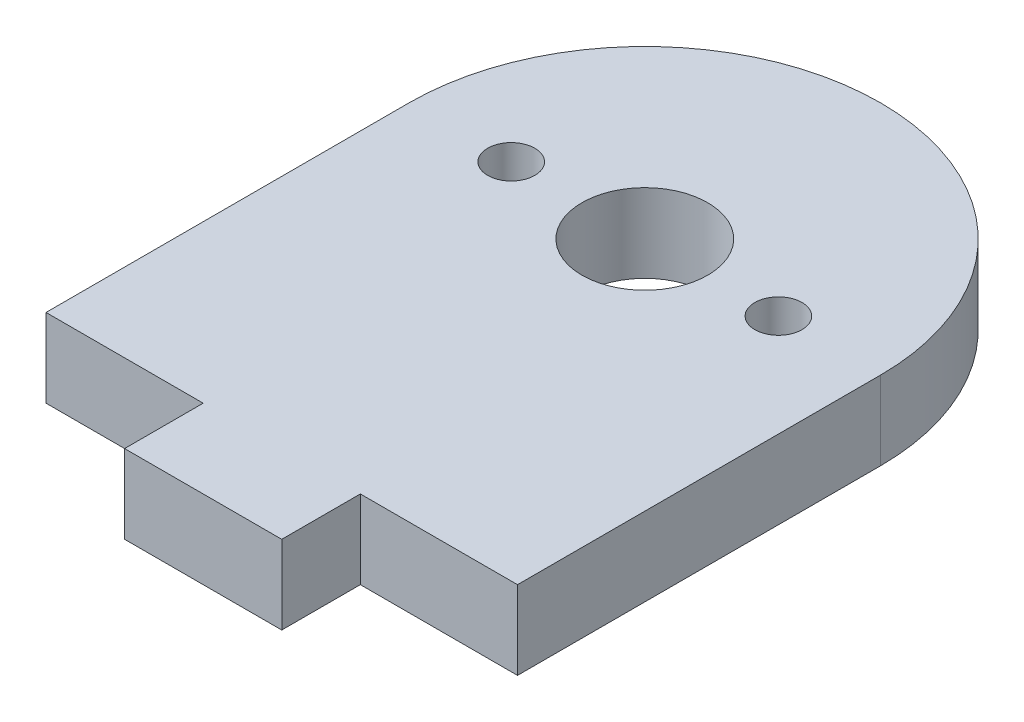
from build123d import *

# Parameters (mm, degrees)
EXTRUDE_1_DEPTH = 5
SKETCH_2_R      = 12.5
SKETCH_2_R_2    = 1.5
SKETCH_2_R_3    = 4
EXTRUDE_2_DEPTH = 5
SKETCH_3_W      = 10
SKETCH_3_H      = 5
EXTRUDE_3_DEPTH = 5


with BuildPart() as part:
    # 草图1 → 凸台-拉伸1 (new body)
    with BuildSketch(Plane(origin=(0, 0, 0), x_dir=(1, 0, 0), z_dir=(0, 1, 0))):
        with BuildLine():
            ThreePointArc((15, 11.55), (0, 26.55), (-15, 11.55))
            Line((-15, 11.55), (-12.5, 11.55))
            ThreePointArc((-12.5, 11.55), (0, 24.05), (12.5, 11.55))
            Line((12.5, 11.55), (15, 11.55))
        make_face()
        with BuildLine():
            Line((-12.5, 11.55), (-15, 11.55))
            ThreePointArc((-15, 11.55), (0, -3.45), (15, 11.55))
            Line((15, 11.55), (12.5, 11.55))
            ThreePointArc((12.5, 11.55), (0, -0.95), (-12.5, 11.55))
        make_face()
        with BuildLine():
            ThreePointArc((15, 11.55), (0, 26.55), (-15, 11.55))
            Line((-15, 11.55), (-12.5, 11.55))
            ThreePointArc((-12.5, 11.55), (0, 24.05), (12.5, 11.55))
            Line((12.5, 11.55), (15, 11.55))
        make_face()
        with BuildLine():
            Line((-12.5, 11.55), (-15, 11.55))
            ThreePointArc((-15, 11.55), (0, -3.45), (15, 11.55))
            Line((15, 11.55), (12.5, 11.55))
            ThreePointArc((12.5, 11.55), (0, -0.95), (-12.5, 11.55))
        make_face()
        with BuildLine():
            Line((-15, 11.55), (-15, -11.55))
            Line((-15, -11.55), (15, -11.55))
            Line((15, -11.55), (15, 11.55))
            ThreePointArc((15, 11.55), (0, -3.45), (-15, 11.55))
        make_face()
    extrude(amount=EXTRUDE_1_DEPTH)

    # 草图2 → 凸台-拉伸2 (add)
    with BuildSketch(Plane(origin=(0, 5, 0), x_dir=(1, 0, 0), z_dir=(0, 1, 0))):
        with Locations((0, 11.55)):
            Circle(SKETCH_2_R)
        with Locations((-8.5, 11.55)):
            Circle(SKETCH_2_R_2, mode=Mode.SUBTRACT)
        with Locations((8.5, 11.55)):
            Circle(SKETCH_2_R_2, mode=Mode.SUBTRACT)
        with Locations((0, 11.55)):
            Circle(SKETCH_2_R_3, mode=Mode.SUBTRACT)
    extrude(amount=-EXTRUDE_2_DEPTH)

    # 草图3 → 凸台-拉伸3 (add)
    with BuildSketch(Plane(origin=(0, 5, 0), x_dir=(1, 0, 0), z_dir=(0, 1, 0))):
        with Locations((0, -14.05)):
            Rectangle(SKETCH_3_W, SKETCH_3_H)
    extrude(amount=-EXTRUDE_3_DEPTH)


solid = part.part
